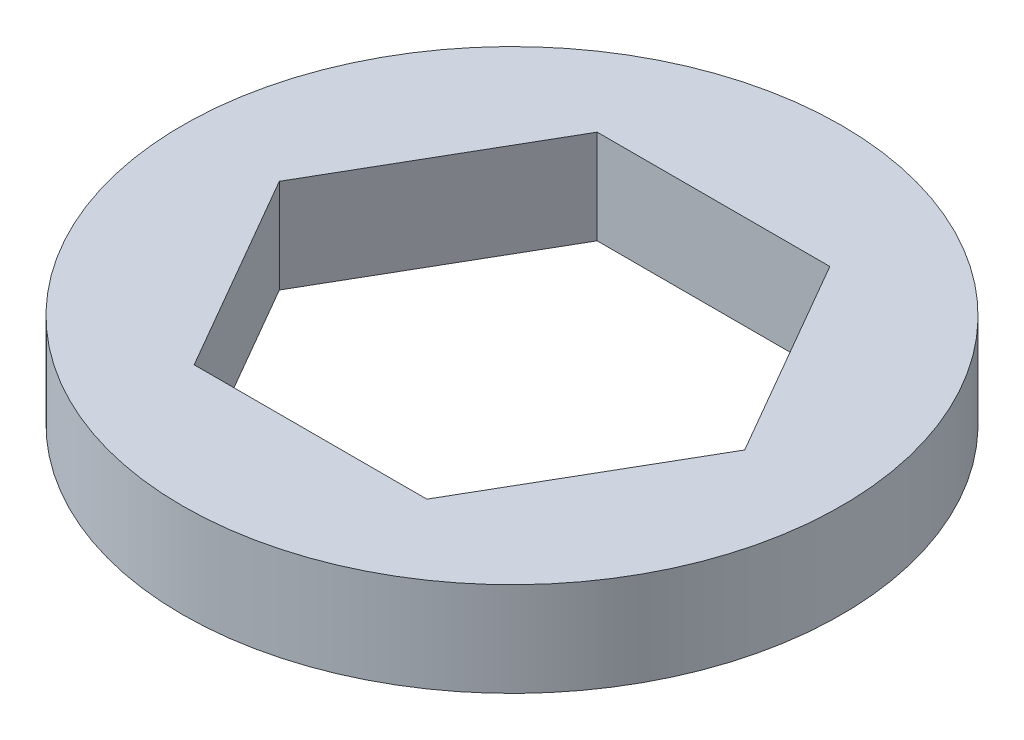
from build123d import *

# Parameters (mm, degrees)
SKETCH1_R           = 11.1125
BOSS_EXTRUDE1_DEPTH = 3.175


with BuildPart() as part:
    # Sketch1 → Boss-Extrude1 (new body)
    with BuildSketch(Plane(origin=(0, 0, 0), x_dir=(1, 0, 0), z_dir=(0, 1, 0))):
        Circle(SKETCH1_R)
        Polygon((7.845612808, 0), (3.922806404, 6.7945), (-3.922806404, 6.7945), (-7.845612808, 0), (-3.922806404, -6.7945), (3.922806404, -6.7945), align=None, mode=Mode.SUBTRACT)
    extrude(amount=BOSS_EXTRUDE1_DEPTH)


solid = part.part
